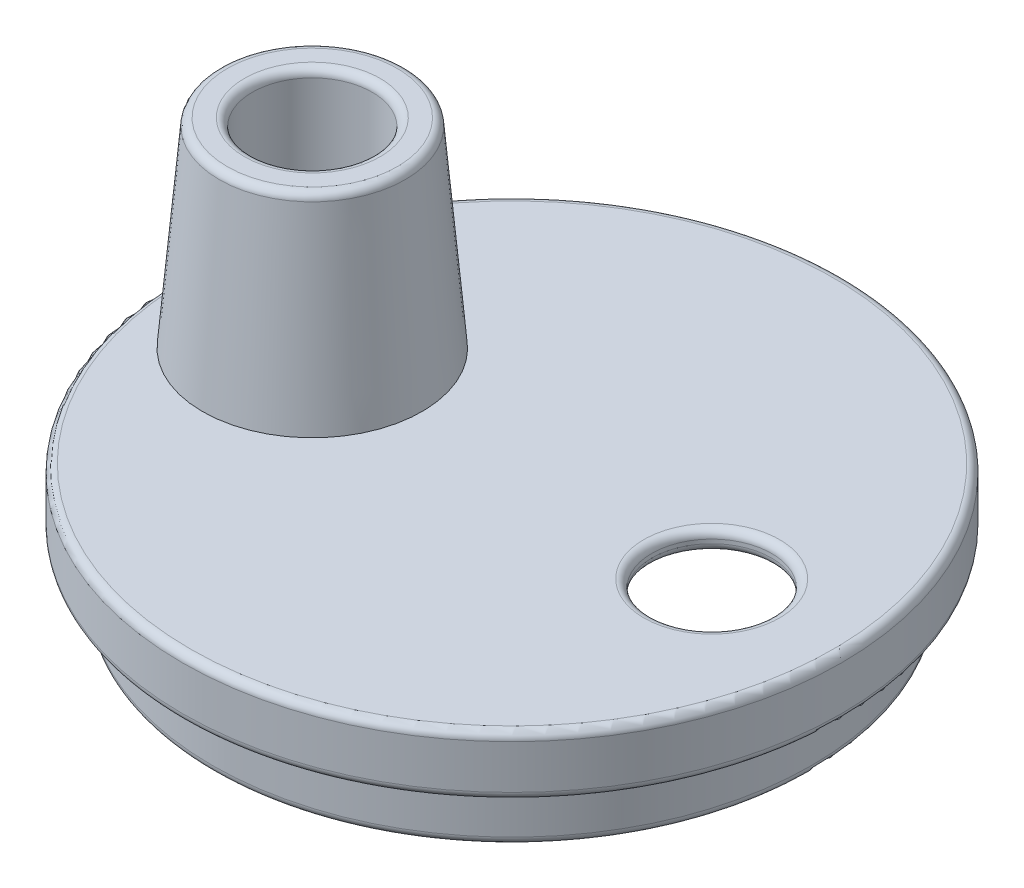
from build123d import *

# Parameters (mm, degrees)
CUT_EXTRUDE1_REACH  = 5
SKETCH2_R           = 1.5
SKETCH3_R           = 2.75
SKETCH3_R_2         = 1.5
BOSS_EXTRUDE1_DEPTH = 5
DRAFT2_ANGLE        = 5
FILLET1_R           = 0.2


with BuildPart() as part:
    # Sketch1 → Revolve1 (revolve)
    with BuildSketch(Plane(origin=(0, 0, 0), x_dir=(0, 0, -1), z_dir=(1, 0, 0))):
        Polygon((-8.25, -1.5), (-7.5, -1.5), (-7.5, -3), (-7, -3), (-7, -1), (-7.75, -1), (-7.75, -0.5), (0, -0.5), (0, 0), (-8.25, 0), align=None)
    revolve(axis=Axis((0, 0, 0), (0, -1, 0)))

    # Sketch2 → Cut-Extrude1 (cut, up to next)
    with BuildSketch(Plane(origin=(0, 0, 0), x_dir=(1, 0, 0), z_dir=(0, 1, 0)), mode=Mode.PRIVATE) as cut_extrude1_sk1:
        with Locations((5, 0)):
            Circle(SKETCH2_R)
    cut_extrude1_tool1 = extrude(cut_extrude1_sk1.sketch, amount=-CUT_EXTRUDE1_REACH, mode=Mode.PRIVATE) & part.part
    add(cut_extrude1_tool1.solids().sort_by_distance((5, 0, 0))[0], mode=Mode.SUBTRACT)
    # Sketch2 → Cut-Extrude1 (cut, up to next)
    with BuildSketch(Plane(origin=(0, 0, 0), x_dir=(1, 0, 0), z_dir=(0, 1, 0)), mode=Mode.PRIVATE) as cut_extrude1_sk2:
        with Locations((-5, 0)):
            Circle(SKETCH2_R)
    cut_extrude1_tool2 = extrude(cut_extrude1_sk2.sketch, amount=-CUT_EXTRUDE1_REACH, mode=Mode.PRIVATE) & part.part
    add(cut_extrude1_tool2.solids().sort_by_distance((-5, 0, 0))[0], mode=Mode.SUBTRACT)

    # Sketch3 → Boss-Extrude1 (add)
    with BuildSketch(Plane(origin=(0, 0, 0), x_dir=(1, 0, 0), z_dir=(0, 1, 0))):
        with Locations((-5, 0)):
            Circle(SKETCH3_R)
        with Locations((-5, 0)):
            Circle(SKETCH3_R_2, mode=Mode.SUBTRACT)
    extrude(amount=BOSS_EXTRUDE1_DEPTH)

    # Draft2
    draft2_faces = [part.faces().sort_by_distance(p)[0] for p in [
        (-7.75, 2.5, 0),
    ]]
    draft(draft2_faces, Plane.ZX, DRAFT2_ANGLE)

    # Fillet1
    fillet1_edges = [part.edges().sort_by_distance(p)[0] for p in [
        (0, -1.5, -8.25),
        (0, 0, -8.25),
        (3.5, -0.5, 0),
        (3.5, 0, 0),
        (-6.5, -0.5, 0),
        (-7.312556682, 5, 0),
        (-6.5, 5, 0),
        (0, -3, -7),
        (0, -3, -7.5),
    ]]
    fillet(fillet1_edges, radius=FILLET1_R)


solid = part.part
